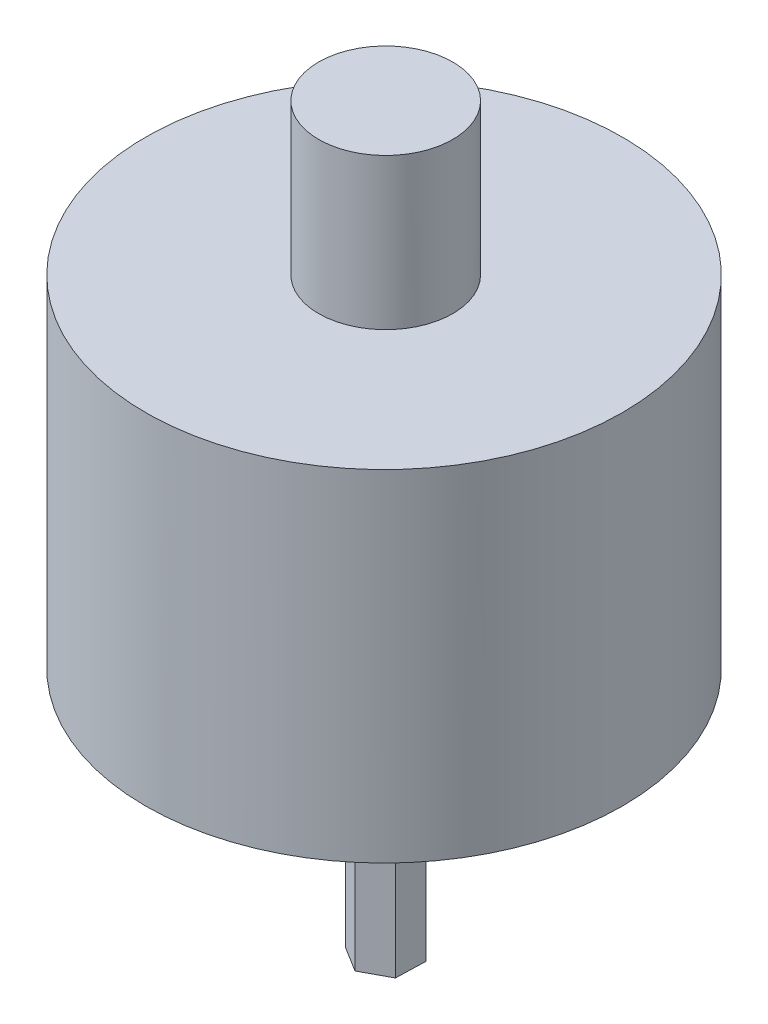
from build123d import *

# Parameters (mm, degrees)
BOSS_EXTRUDE1_DEPTH = 8.305
SKETCH2_R           = 8
BOSS_EXTRUDE2_DEPTH = 11.43
SKETCH3_R           = 2.25
BOSS_EXTRUDE3_DEPTH = 5.06


with BuildPart() as part:
    # Sketch1 → Boss-Extrude1 (new body)
    with BuildSketch(Plane(origin=(0, 0, 0), x_dir=(1, 0, 0), z_dir=(0, 1, 0))):
        Polygon((17.034949463, -13.137071019), (17.914502801, -12.66376429), (17.944383819, -11.665395391), (17.094711499, -11.140333221), (16.215158161, -11.61363995), (16.185277144, -12.612008849), align=None)
    extrude(amount=BOSS_EXTRUDE1_DEPTH)

    # Sketch2 → Boss-Extrude2 (add)
    with BuildSketch(Plane(origin=(0, 8.305, 0), x_dir=(1, 0, 0), z_dir=(0, 1, 0))):
        with Locations((17.034949463, -12.16457984)):
            Circle(SKETCH2_R)
    extrude(amount=BOSS_EXTRUDE2_DEPTH)

    # Sketch3 → Boss-Extrude3 (add)
    with BuildSketch(Plane(origin=(0, 19.735, 0), x_dir=(1, 0, 0), z_dir=(0, 1, 0))):
        with Locations((17.064830481, -12.13870212)):
            Circle(SKETCH3_R)
    extrude(amount=BOSS_EXTRUDE3_DEPTH)


solid = part.part
